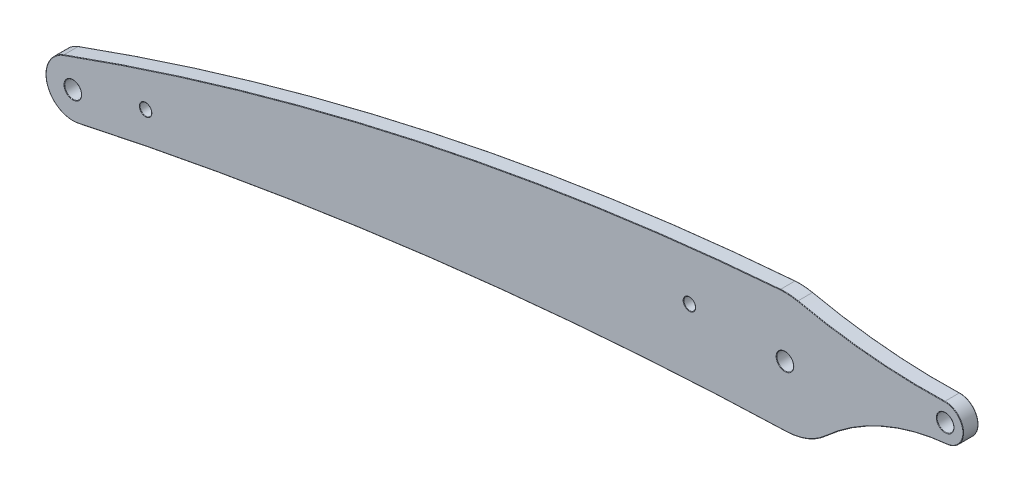
from build123d import *

# Parameters (mm, degrees)
SKETCH1_R           = 2.8
SKETCH1_R_2         = 1.95
BOSS_EXTRUDE1_DEPTH = 5
FILLET1_R           = 0.15


with BuildPart() as part:
    # Sketch1 → Boss-Extrude1 (new body)
    with BuildSketch(Plane.XY):
        with BuildLine():
            ThreePointArc((-276.780298859, 247.280879976), (-159.458245776, 281.177252724), (-38.627454071, 298.878891089))
            ThreePointArc((-38.627454071, 298.878891089), (-35.703409549, 298.891758843), (-32.808740213, 298.478126912))
            ThreePointArc((-32.808740213, 298.478126912), (-8.553336403, 294.720430459), (15.979700244, 293.96213667))
            ThreePointArc((15.979700244, 293.96213667), (22.150729095, 288.343420795), (16.736284207, 281.992408929))
            ThreePointArc((16.736284207, 281.992408929), (-4.892396072, 276.328147292), (-23.631877288, 264.133250235))
            ThreePointArc((-23.631877288, 264.133250235), (-29.582680643, 260.39649995), (-36.45865167, 258.948609866))
            ThreePointArc((-36.45865167, 258.948609866), (-154.786824819, 249.865033835), (-271.793567605, 230.028450028))
            ThreePointArc((-271.793567605, 230.028450028), (-282.347428026, 236.324818051), (-276.780298859, 247.280879976))
        make_face()
        with Locations((-273.701360714, 238.8239219)):
            Circle(SKETCH1_R, mode=Mode.SUBTRACT)
        with Locations((-249.527266647, 245.196768675)):
            Circle(SKETCH1_R_2, mode=Mode.SUBTRACT)
        with Locations((-68.827654746, 279.587808188)):
            Circle(SKETCH1_R_2, mode=Mode.SUBTRACT)
        with Locations((-37.077654746, 278.93902845)):
            Circle(SKETCH1_R, mode=Mode.SUBTRACT)
        with Locations((16.162679097, 287.964927424)):
            Circle(SKETCH1_R, mode=Mode.SUBTRACT)
    extrude(amount=-BOSS_EXTRUDE1_DEPTH)

    # Fillet1
    fillet1_edges = [part.edges().sort_by_distance(p)[0] for p in [
        (-4.892396072, 276.328147292, 0),
        (-29.582680643, 260.39649995, 0),
        (-154.786824819, 249.865033835, 0),
        (-282.347428026, 236.324818051, 0),
        (-29.582680643, 260.39649995, -5),
        (-4.892396072, 276.328147292, -5),
        (22.150729095, 288.343420795, -5),
        (-276.501360714, 238.8239219, -5),
        (-276.501360714, 238.8239219, 0),
        (-8.553336403, 294.720430459, -5),
        (-251.477266647, 245.196768675, -5),
        (-251.477266647, 245.196768675, 0),
        (-35.703409549, 298.891758843, -5),
        (-70.777654746, 279.587808188, -5),
        (-70.777654746, 279.587808188, 0),
        (-159.458245776, 281.177252724, -5),
        (-39.877654746, 278.93902845, -5),
        (-39.877654746, 278.93902845, 0),
        (13.362679097, 287.964927424, -5),
        (13.362679097, 287.964927424, 0),
        (-282.347428026, 236.324818051, -5),
        (-159.458245776, 281.177252724, 0),
        (-154.786824819, 249.865033835, -5),
        (-35.703409549, 298.891758843, 0),
        (-8.553336403, 294.720430459, 0),
        (22.150729095, 288.343420795, 0),
    ]]
    fillet(fillet1_edges, radius=FILLET1_R)


solid = part.part
